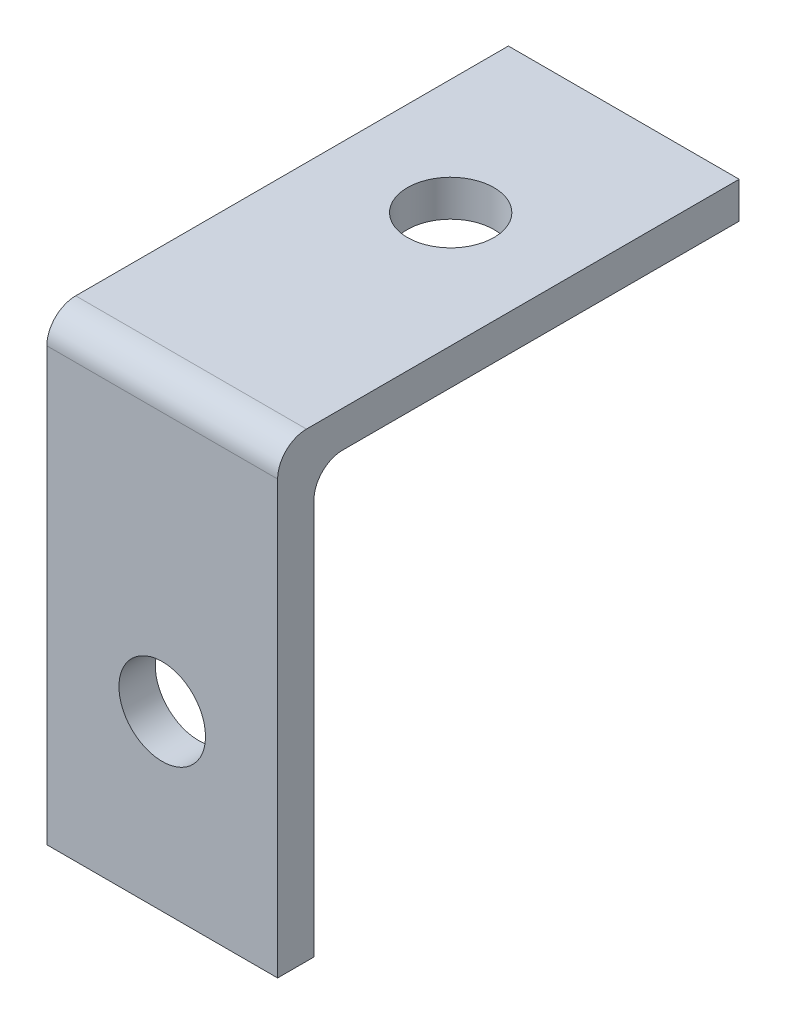
from build123d import *

# Parameters (mm, degrees)
CROQUIS1_W              = 12.7
CROQUIS1_H              = 25.4
SALIENTE_EXTRUIR1_DEPTH = 2
CROQUIS2_W              = 12.7
CROQUIS2_H              = 2
SALIENTE_EXTRUIR2_DEPTH = 23.368
REDONDEO1_R             = 1.5875
CROQUIS3_R              = 2.38125
CORTAR_EXTRUIR1_DEPTH   = 26.368
CROQUIS4_R              = 2.38125
CORTAR_EXTRUIR2_DEPTH   = 2.54


with BuildPart() as part:
    # Croquis1 → Saliente-Extruir1 (new body)
    with BuildSketch(Plane(origin=(0, 0, 0), x_dir=(1, 0, 0), z_dir=(0, 1, 0))):
        Rectangle(CROQUIS1_W, CROQUIS1_H)
    extrude(amount=SALIENTE_EXTRUIR1_DEPTH)

    # Croquis2 → Saliente-Extruir2 (add)
    with BuildSketch(Plane.XZ):
        with Locations((0, 11.7)):
            Rectangle(CROQUIS2_W, CROQUIS2_H)
    extrude(amount=SALIENTE_EXTRUIR2_DEPTH)

    # Redondeo1
    redondeo1_edges = [part.edges().sort_by_distance(p)[0] for p in [
        (0, 2, 12.7),
        (0, 0, 10.7),
    ]]
    fillet(redondeo1_edges, radius=REDONDEO1_R)

    # Croquis3 → Cortar-Extruir1 (cut, through all)
    with BuildSketch(Plane(origin=(0, 2, 0), x_dir=(1, 0, 0), z_dir=(0, 1, 0))):
        with Locations((0, 3.175)):
            Circle(CROQUIS3_R)
    extrude(amount=-CORTAR_EXTRUIR1_DEPTH, mode=Mode.SUBTRACT)

    # Croquis4 → Cortar-Extruir2 (cut)
    with BuildSketch(Plane.XY.offset(12.7)):
        with Locations((0, -13.843)):
            Circle(CROQUIS4_R)
    extrude(amount=-CORTAR_EXTRUIR2_DEPTH, mode=Mode.SUBTRACT)


solid = part.part
